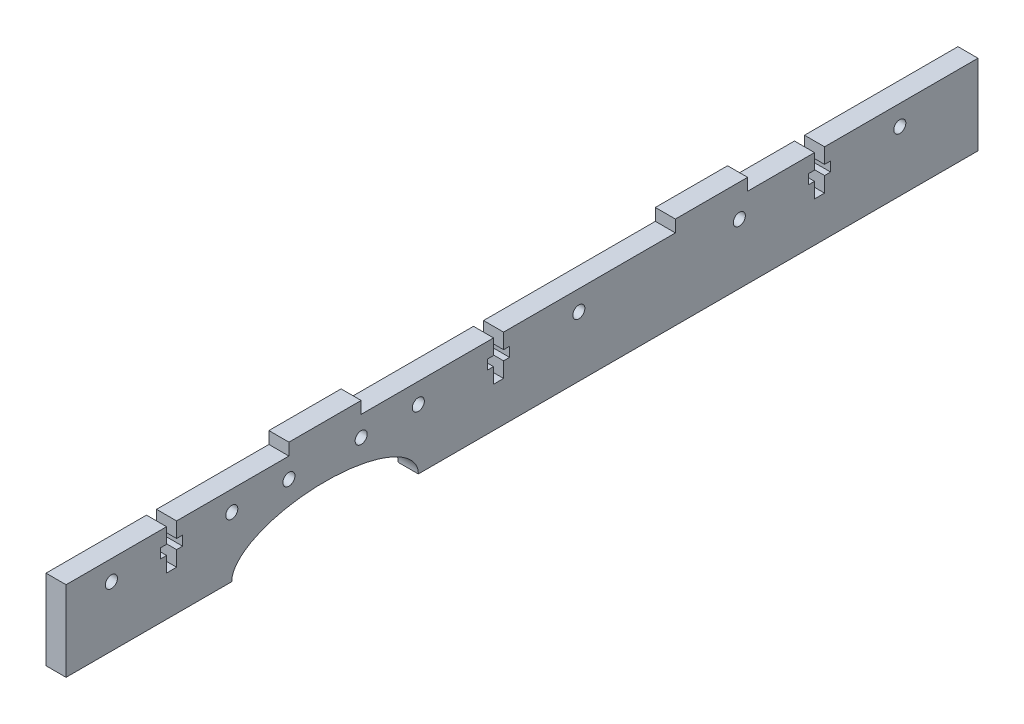
from build123d import *

# Parameters (mm, degrees)
ESTRUSIONE_ESTRUSIONE1_DEPTH = 5
SCHIZZO3_R                   = 1.5
SCHIZZO3_RX                  = 23.25
SCHIZZO3_RY                  = 10
TAGLIO_ESTRUSIONE1_DEPTH     = 6
TAGLIO_ESTRUSIONE2_DEPTH     = 6.0000001
SCHIZZO6_W                   = 5
SCHIZZO6_H                   = 18
ESTRUSIONE_ESTRUSIONE2_DEPTH = 3


with BuildPart() as part:
    # Schizzo1 → Estrusione-Estrusione1 (new body)
    with BuildSketch(Plane(origin=(0, 0, 0), x_dir=(0, 0, -1), z_dir=(1, 0, 0))):
        Polygon((-113.645, -10), (113.645, -10), (113.645, 10), (-40.095, 10), (-40.095, 13), (-58.095, 13), (-58.095, 10), (-113.645, 10), align=None)
    extrude(amount=ESTRUSIONE_ESTRUSIONE1_DEPTH)

    # Schizzo3 → Taglio-Estrusione1 (cut, through all)
    with BuildSketch(Plane(origin=(0, 0, 0), x_dir=(0, 0, -1), z_dir=(1, 0, 0))):
        with Locations((-58.095, 5)):
            Circle(SCHIZZO3_R)
        with Locations((-72.345, 5)):
            Circle(SCHIZZO3_R)
        with Locations((-40.095, 5)):
            Circle(SCHIZZO3_R)
        with Locations((-25.845, 5)):
            Circle(SCHIZZO3_R)
        with Locations((14.155, 5)):
            Circle(SCHIZZO3_R)
        with Locations((54.155, 5)):
            Circle(SCHIZZO3_R)
        with Locations((94.155, 5)):
            Circle(SCHIZZO3_R)
        with Locations((-102.345, 5)):
            Circle(SCHIZZO3_R)
        with Locations(Location((-49.095, -10), (0, 0, 0))):
            Ellipse(SCHIZZO3_RX, SCHIZZO3_RY)
    extrude(amount=TAGLIO_ESTRUSIONE1_DEPTH, mode=Mode.SUBTRACT)

    # Schizzo5 → Taglio-Estrusione2 (cut, through all)
    with BuildSketch(Plane(origin=(0, 0, 0), x_dir=(0, 0, -1), z_dir=(1, 0, 0))):
        Polygon((-88.595, 0), (-88.595, 3.8), (-90.095, 3.8), (-90.095, 6.2), (-88.595, 6.2), (-88.595, 10), (-86.095, 10), (-86.095, 6.2), (-84.595, 6.2), (-84.595, 3.8), (-86.095, 3.8), (-86.095, 0), align=None)
        Polygon((-7.095, 0), (-7.095, 3.8), (-8.595, 3.8), (-8.595, 6.2), (-7.095, 6.2), (-7.095, 10), (-4.595, 10), (-4.595, 6.2), (-3.095, 6.2), (-3.095, 3.8), (-4.595, 3.8), (-4.595, 0), align=None)
        Polygon((72.905, 0), (72.905, 3.8), (71.405, 3.8), (71.405, 6.2), (72.905, 6.2), (72.905, 10), (75.405, 10), (75.405, 6.2), (76.905, 6.2), (76.905, 3.8), (75.405, 3.8), (75.405, 0), align=None)
    extrude(amount=TAGLIO_ESTRUSIONE2_DEPTH, mode=Mode.SUBTRACT)

    # Schizzo6 → Estrusione-Estrusione2 (add)
    with BuildSketch(Plane(origin=(0, 10, 0), x_dir=(1, 0, 0), z_dir=(0, 1, 0))):
        with Locations((2.5, 47.225)):
            Rectangle(SCHIZZO6_W, SCHIZZO6_H)
    extrude(amount=ESTRUSIONE_ESTRUSIONE2_DEPTH)


solid = part.part
